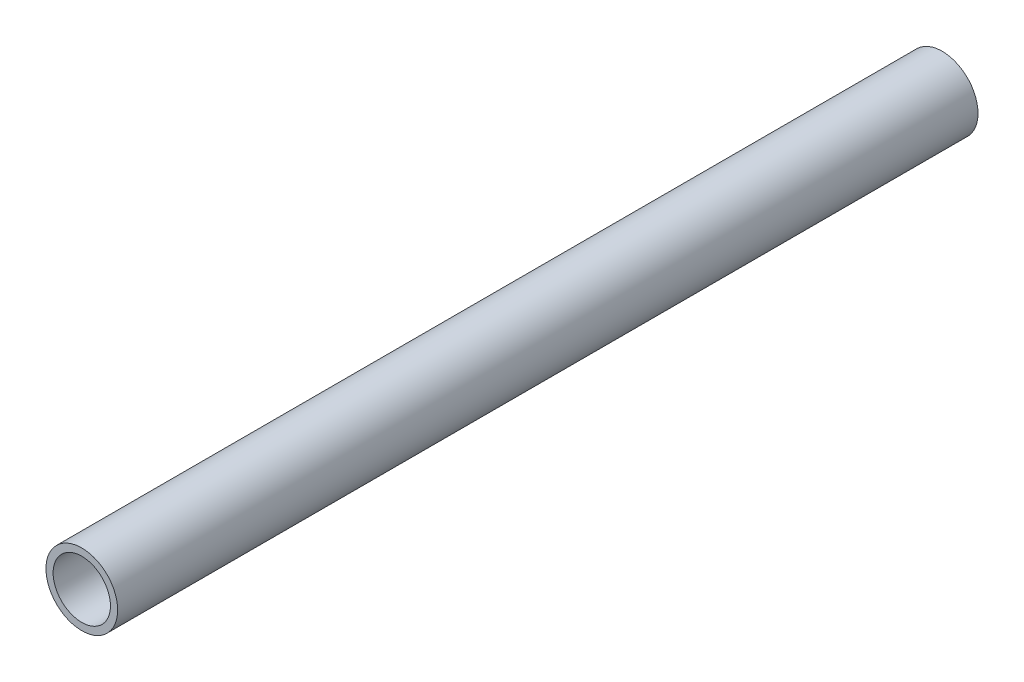
from build123d import *

# Parameters (mm, degrees)
SKETCH2_R           = 15.875
SKETCH2_R_2         = 12.7
BOSS_EXTRUDE1_DEPTH = 190.5


with BuildPart() as part:
    # Sketch2 → Boss-Extrude1 (new body, symmetric)
    with BuildSketch(Plane.XY):
        Circle(SKETCH2_R)
        Circle(SKETCH2_R_2, mode=Mode.SUBTRACT)
    extrude(amount=BOSS_EXTRUDE1_DEPTH, both=True)


solid = part.part
